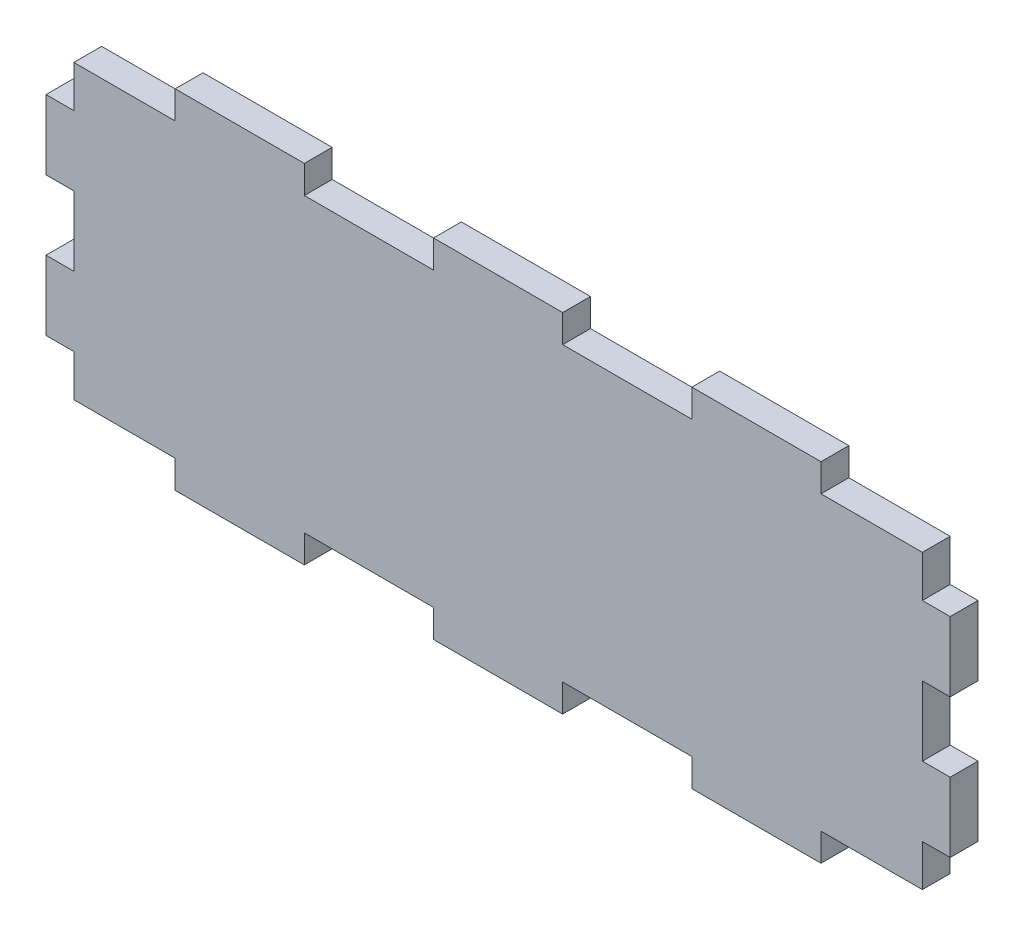
from build123d import *

# Parameters (mm, degrees)
BUITENAFMETING_RECHTHOEK_W  = 130
BUITENAFMETING_RECHTHOEK_H  = 50
PLAAT_DEPTH                 = 4
TAND_HOR_W                  = 18.571428571
TAND_HOR_H                  = 4
TAND_BOVEN_DEPTH            = 5
TANDEN_PATROON_BOVEN_COUNT  = 4
TANDEN_PATROON_BOVEN_PITCH  = 37.142857143
TAND_VER_W                  = 4
TAND_VER_H                  = 10
TAND_LINKS_DEPTH            = 5
TANDEN_PATROON_LINKS_COUNT  = 3
TANDEN_PATROON_LINKS_PITCH  = 20
TAND_O_W                    = 18.571428571
TAND_O_H                    = 4
TAND_ONDER_DEPTH            = 5
TANDEN_PATROON_ONDER_COUNT  = 4
TANDEN_PATROON_ONDER_PITCH  = 37.142857143
TAND_R_W                    = 4
TAND_R_H                    = 10
TAND_RECHTS_DEPTH           = 5
TANDEN_PATROON_RECHTS_COUNT = 3
TANDEN_PATROON_RECHTS_PITCH = 20


with BuildPart() as part:
    # Buitenafmeting Rechthoek → Plaat (new body)
    with BuildSketch(Plane.XY):
        with Locations((65, 25)):
            Rectangle(BUITENAFMETING_RECHTHOEK_W, BUITENAFMETING_RECHTHOEK_H)
    extrude(amount=-PLAAT_DEPTH)

    # Tand Hor → Tand Boven (cut, through all)
    with BuildSketch(Plane.XY):
        with Locations((9.285714286, 48)):
            Rectangle(TAND_HOR_W, TAND_HOR_H)
    tand_boven = extrude(amount=-TAND_BOVEN_DEPTH, mode=Mode.SUBTRACT)

    # Tanden Patroon Boven: Tand Boven ×4
    with Locations(*[(i * TANDEN_PATROON_BOVEN_PITCH, 0, 0) for i in range(1, TANDEN_PATROON_BOVEN_COUNT)]):
        add(tand_boven, mode=Mode.SUBTRACT)

    # Tand Ver → Tand Links (cut, through all)
    with BuildSketch(Plane.XY):
        with Locations((2, 45)):
            Rectangle(TAND_VER_W, TAND_VER_H)
    tand_links = extrude(amount=-TAND_LINKS_DEPTH, mode=Mode.SUBTRACT)

    # Tanden Patroon Links: Tand Links ×3
    with Locations(*[(0, -i * TANDEN_PATROON_LINKS_PITCH, 0) for i in range(1, TANDEN_PATROON_LINKS_COUNT)]):
        add(tand_links, mode=Mode.SUBTRACT)

    # Tand O → Tand Onder (cut, through all)
    with BuildSketch(Plane.XY):
        with Locations((9.285714286, 2)):
            Rectangle(TAND_O_W, TAND_O_H)
    tand_onder = extrude(amount=-TAND_ONDER_DEPTH, mode=Mode.SUBTRACT)

    # Tanden Patroon Onder: Tand Onder ×4
    with Locations(*[(i * TANDEN_PATROON_ONDER_PITCH, 0, 0) for i in range(1, TANDEN_PATROON_ONDER_COUNT)]):
        add(tand_onder, mode=Mode.SUBTRACT)

    # Tand R → Tand Rechts (cut, through all)
    with BuildSketch(Plane.XY):
        with Locations((128, 45)):
            Rectangle(TAND_R_W, TAND_R_H)
    tand_rechts = extrude(amount=-TAND_RECHTS_DEPTH, mode=Mode.SUBTRACT)

    # Tanden Patroon Rechts: Tand Rechts ×3
    with Locations(*[(0, -i * TANDEN_PATROON_RECHTS_PITCH, 0) for i in range(1, TANDEN_PATROON_RECHTS_COUNT)]):
        add(tand_rechts, mode=Mode.SUBTRACT)


solid = part.part
